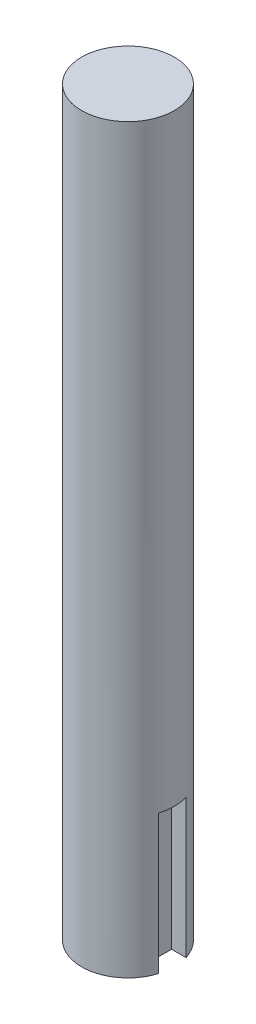
from build123d import *

# Parameters (mm, degrees)
SKETCH1_R           = 10
BOSS_EXTRUDE1_DEPTH = 160
CUT_EXTRUDE1_DEPTH  = 30


with BuildPart() as part:
    # Sketch1 → Boss-Extrude1 (new body)
    with BuildSketch(Plane(origin=(0, 0, 0), x_dir=(1, 0, 0), z_dir=(0, 1, 0))):
        Circle(SKETCH1_R)
    extrude(amount=BOSS_EXTRUDE1_DEPTH)

    # Sketch1_3 → Cut-Extrude1 (cut)
    with BuildSketch(Plane(origin=(0, 0, 0), x_dir=(1, 0, 0), z_dir=(0, 1, 0))):
        with BuildLine():
            Line((9.539392014, 3), (6.409392014, 3))
            Line((6.409392014, 3), (6.409392014, -3))
            Line((6.409392014, -3), (9.539392014, -3))
            ThreePointArc((9.539392014, -3), (9.884177258, -1.517576993), (10, 0))
            ThreePointArc((10, 0), (9.884177258, 1.517576993), (9.539392014, 3))
        make_face()
    extrude(amount=CUT_EXTRUDE1_DEPTH, mode=Mode.SUBTRACT)


solid = part.part
